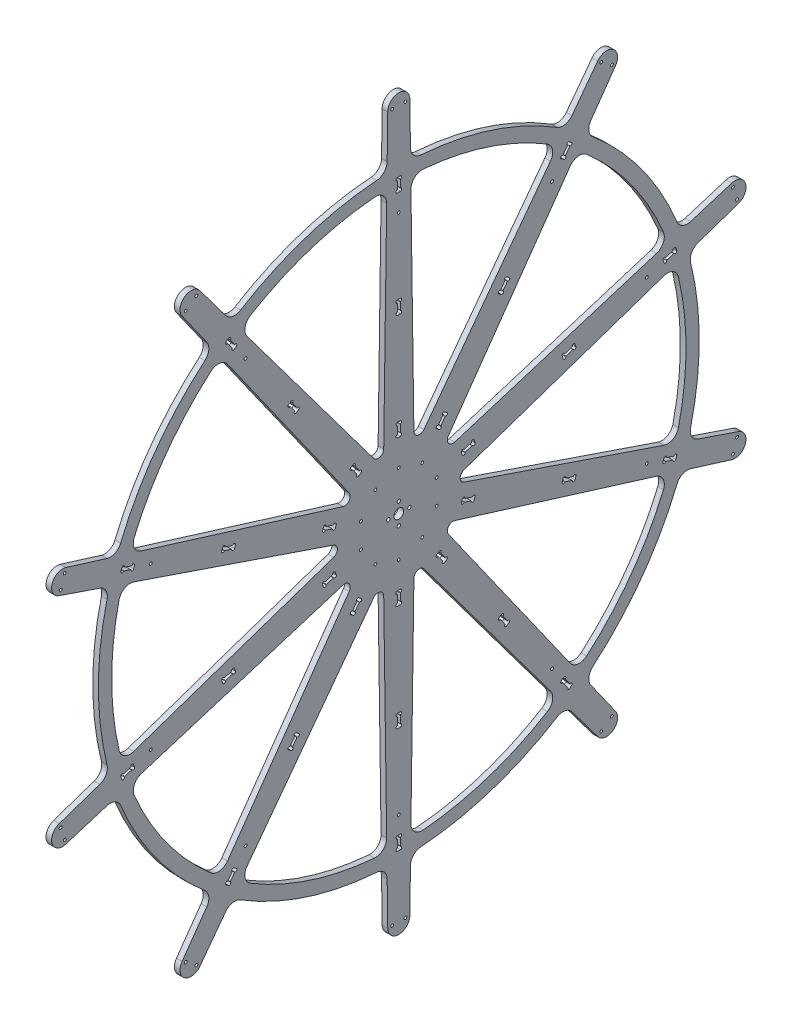
from build123d import *

# Parameters (mm, degrees)
SKETCH1_R                    = 45
BOSS_EXTRUDE1_DEPTH          = 3.175
BOSS_EXTRUDE2_START          = 3.175
SKETCH1_4_R                  = 1.5875
BOSS_EXTRUDE2_DEPTH          = 6.35
BOSS_EXTRUDE3_START          = 3.175
SKETCH2_R                    = 340
SKETCH2_R_2                  = 325
BOSS_EXTRUDE3_DEPTH          = 6.35
SKETCH1_5_R                  = 1.5875
SKETCH1_5_W                  = 3.375
SKETCH1_5_H                  = 15.2
CUT_EXTRUDE1_DEPTH           = 4.175
FILLET3_R                    = 12.7
FILLET4_R                    = 0.5
F_1_8_0_125_DIAMETER_HOLE1_D = 3.175
CIRPATTERN1_COUNT            = 10
FILLET3_OF_CIRPATTERN1_R     = 12.7
FILLET4_OF_CIRPATTERN1_R     = 0.5
M4_CLEARANCE_HOLE1_D         = 4
CIRPATTERN2_COUNT            = 4
F_1_8_0_125_DIAMETER_HOLE2_D = 3.175
SKETCH7_R                    = 5.5
CUT_EXTRUDE2_DEPTH           = 1
CUT_EXTRUDE2_DEPTH_BACK      = 7.35
FILLET1_R                    = 6.35
CIRPATTERN3_COUNT            = 10


with BuildPart() as part:
    # Sketch1 → Boss-Extrude1 (new body, symmetric)
    with BuildSketch(Plane(origin=(0, 0, 0), x_dir=(0, 0, -1), z_dir=(1, 0, 0))):
        Circle(SKETCH1_R)
    extrude(amount=BOSS_EXTRUDE1_DEPTH, both=True)

    # Sketch1_4 → Boss-Extrude2 (add)
    with BuildSketch(Plane(origin=(0, 0, 0), x_dir=(0, 0, -1), z_dir=(1, 0, 0)).offset(BOSS_EXTRUDE2_START)):
        with BuildLine():
            Line((12.5, -400), (17.5, -41.457809879))
            ThreePointArc((17.5, -41.457809879), (0, -45), (-17.5, -41.457809879))
            Line((-17.5, -41.457809879), (-12.5, -400))
            ThreePointArc((-12.5, -400), (0, -412.5), (12.5, -400))
        make_face()
        with Locations((-1.6875, -88.6125)):
            Circle(SKETCH1_4_R, mode=Mode.SUBTRACT)
        with Locations((-1.6875, -76.5875)):
            Circle(SKETCH1_4_R, mode=Mode.SUBTRACT)
        with Locations((1.6875, -76.5875)):
            Circle(SKETCH1_4_R, mode=Mode.SUBTRACT)
        with Locations((1.6875, -88.6125)):
            Circle(SKETCH1_4_R, mode=Mode.SUBTRACT)
        with Locations((-1.6875, -328.6125)):
            Circle(SKETCH1_4_R, mode=Mode.SUBTRACT)
        with Locations((-1.6875, -316.5875)):
            Circle(SKETCH1_4_R, mode=Mode.SUBTRACT)
        with Locations((1.6875, -316.5875)):
            Circle(SKETCH1_4_R, mode=Mode.SUBTRACT)
        with Locations((1.6875, -328.6125)):
            Circle(SKETCH1_4_R, mode=Mode.SUBTRACT)
        with Locations((-1.6875, -208.6125)):
            Circle(SKETCH1_4_R, mode=Mode.SUBTRACT)
        with Locations((-1.6875, -196.5875)):
            Circle(SKETCH1_4_R, mode=Mode.SUBTRACT)
        with Locations((1.6875, -196.5875)):
            Circle(SKETCH1_4_R, mode=Mode.SUBTRACT)
        with Locations((1.6875, -208.6125)):
            Circle(SKETCH1_4_R, mode=Mode.SUBTRACT)
    boss_extrude2 = extrude(amount=-BOSS_EXTRUDE2_DEPTH)

    # Sketch2 → Boss-Extrude3 (add)
    with BuildSketch(Plane(origin=(0, 0, 0), x_dir=(0, 0, -1), z_dir=(1, 0, 0)).offset(BOSS_EXTRUDE3_START)):
        Circle(SKETCH2_R)
        Circle(SKETCH2_R_2, mode=Mode.SUBTRACT)
    extrude(amount=-BOSS_EXTRUDE3_DEPTH)

    # Sketch1_5 → Cut-Extrude1 (cut, symmetric)
    with BuildSketch(Plane(origin=(0, 0, 0), x_dir=(0, 0, -1), z_dir=(1, 0, 0))):
        with Locations((-1.6875, -328.6125)):
            Circle(SKETCH1_5_R)
        with Locations((1.6875, -328.6125)):
            Circle(SKETCH1_5_R)
        with Locations((0, -202.6)):
            Rectangle(SKETCH1_5_W, SKETCH1_5_H)
        with Locations((0, -82.6)):
            Rectangle(SKETCH1_5_W, SKETCH1_5_H)
        with Locations((0, -322.6)):
            Rectangle(SKETCH1_5_W, SKETCH1_5_H)
    cut_extrude1 = extrude(amount=CUT_EXTRUDE1_DEPTH, both=True, mode=Mode.SUBTRACT)

    # Fillet3
    fillet3_edges = [part.edges().sort_by_distance(p)[0] for p in [
        (0, -324.717418323, 13.549842721),
        (0, -339.73818516, 13.340372716),
        (0, -324.717418323, -13.549842721),
        (0, -339.73818516, -13.340372716),
    ]]
    fillet(fillet3_edges, radius=FILLET3_R)

    # Fillet4
    fillet4_edges = [part.edges().sort_by_distance(p)[0] for p in [
        (0, -87.025, 1.6875),
        (0, -87.025, -1.6875),
        (0, -198.175, -1.6875),
        (0, -198.175, 1.6875),
        (0, -327.025, 1.6875),
        (0, -327.025, -1.6875),
        (0, -207.025, 1.6875),
        (0, -78.175, -1.6875),
        (0, -318.175, -1.6875),
        (0, -318.175, 1.6875),
        (0, -207.025, -1.6875),
        (0, -78.175, 1.6875),
    ]]
    fillet(fillet4_edges, radius=FILLET4_R)

    # 1_8 _0.125_ Diameter Hole1 (through all)
    with Locations(Plane(origin=(3.175, 0, 0), x_dir=(0, 0, -1), z_dir=(1, 0, 0))):
        with Locations((-7.5, -400), (7.5, -400)):
            f_1_8_0_125_diameter_hole1 = Hole(F_1_8_0_125_DIAMETER_HOLE1_D / 2)

    # CirPattern1: Boss-Extrude2, Cut-Extrude1, 1_8 _0.125_ Diameter Hole1 ×10 about axis
    cirpattern1_axis = Axis((0, 0, 0), (1, 0, 0))
    for i in range(1, CIRPATTERN1_COUNT):
        add(boss_extrude2.rotate(cirpattern1_axis, i * 360 / CIRPATTERN1_COUNT))
        add(cut_extrude1.rotate(cirpattern1_axis, i * 360 / CIRPATTERN1_COUNT), mode=Mode.SUBTRACT)
        add(f_1_8_0_125_diameter_hole1.rotate(cirpattern1_axis, i * 360 / CIRPATTERN1_COUNT), mode=Mode.SUBTRACT)

    # Fillet3 of CirPattern1
    fillet3_of_cirpattern1_edges = [part.edges().sort_by_distance(p)[0] for p in [
        (0, -270.666307515, -179.90205662),
        (0, -282.695239775, -188.900506639),
        (0, -254.737512071, -201.826162685),
        (0, -267.01269109, -210.485683116),
        (0, -113.229866846, -304.637484979),
        (0, -117.672321254, -318.98781295),
        (0, -87.456534417, -313.011748322),
        (0, -92.297424451, -327.232616711),
        (0, 87.456534417, -313.011748322),
        (0, 92.297424451, -327.232616711),
        (0, 113.229866846, -304.637484979),
        (0, 117.672321254, -318.98781295),
        (0, 254.737512071, -201.826162685),
        (0, 267.01269109, -210.485683116),
        (0, 270.666307515, -179.90205662),
        (0, 282.695239775, -188.900506639),
        (0, 324.717418323, -13.549842721),
        (0, 339.73818516, -13.340372716),
        (0, 324.717418323, 13.549842721),
        (0, 339.73818516, 13.340372716),
        (0, 270.666307515, 179.90205662),
        (0, 282.695239775, 188.900506639),
        (0, 254.737512071, 201.826162685),
        (0, 267.01269109, 210.485683116),
        (0, 113.229866846, 304.637484979),
        (0, 117.672321254, 318.98781295),
        (0, 87.456534417, 313.011748322),
        (0, 92.297424451, 327.232616711),
        (0, -87.456534417, 313.011748322),
        (0, -92.297424451, 327.232616711),
        (0, -113.229866846, 304.637484979),
        (0, -117.672321254, 318.98781295),
        (0, -254.737512071, 201.826162685),
        (0, -267.01269109, 210.485683116),
        (0, -270.666307515, 179.90205662),
        (0, -282.695239775, 188.900506639),
    ]]
    fillet(fillet3_of_cirpattern1_edges, radius=FILLET3_OF_CIRPATTERN1_R)

    # Fillet4 of CirPattern1
    fillet4_of_cirpattern1_edges = [part.edges().sort_by_distance(p)[0] for p in [
        (0, -71.396591549, -49.786795403),
        (0, -69.412816322, -52.517227759),
        (0, -159.335055247, -117.849558551),
        (0, -161.318830473, -115.119126195),
        (0, -265.560670199, -190.855255953),
        (0, -263.576894972, -193.585688309),
        (0, -168.478630874, -120.321025678),
        (0, -62.253015922, -47.315328276),
        (0, -256.417094572, -188.383788826),
        (0, -258.400869798, -185.65335647),
        (0, -166.494855647, -123.051458034),
        (0, -64.236791149, -44.58489592),
        (0, -28.497111807, -82.244227153),
        (0, -25.287296064, -83.287159509),
        (0, -59.634534989, -188.997091295),
        (0, -62.844350731, -187.954158939),
        (0, -102.661190457, -310.497791063),
        (0, -99.451374714, -311.540723419),
        (0, -65.579151132, -196.371009108),
        (0, -22.552495664, -74.870309339),
        (0, -96.716574314, -303.12387325),
        (0, -99.926390056, -302.080940894),
        (0, -62.369335389, -197.413941464),
        (0, -25.762311407, -73.827376983),
        (0, 25.287296064, -83.287159509),
        (0, 28.497111807, -82.244227153),
        (0, 62.844350732, -187.954158939),
        (0, 59.634534989, -188.997091295),
        (0, 99.451374714, -311.540723419),
        (0, 102.661190457, -310.497791063),
        (0, 62.369335389, -197.413941464),
        (0, 25.762311407, -73.827376983),
        (0, 99.926390057, -302.080940894),
        (0, 96.716574314, -303.12387325),
        (0, 65.579151132, -196.371009108),
        (0, 22.552495664, -74.870309339),
        (0, 69.412816322, -52.517227759),
        (0, 71.396591549, -49.786795403),
        (0, 161.318830474, -115.119126195),
        (0, 159.335055247, -117.849558551),
        (0, 263.576894972, -193.585688309),
        (0, 265.560670199, -190.855255953),
        (0, 166.494855647, -123.051458034),
        (0, 64.236791149, -44.58489592),
        (0, 258.400869799, -185.65335647),
        (0, 256.417094572, -188.383788826),
        (0, 168.478630874, -120.321025678),
        (0, 62.253015922, -47.315328276),
        (0, 87.025, -1.6875),
        (0, 87.025, 1.6875),
        (0, 198.175, 1.6875),
        (0, 198.175, -1.6875),
        (0, 327.025, -1.6875),
        (0, 327.025, 1.6875),
        (0, 207.025, -1.6875),
        (0, 78.175, 1.6875),
        (0, 318.175, 1.6875),
        (0, 318.175, -1.6875),
        (0, 207.025, 1.6875),
        (0, 78.175, -1.6875),
        (0, 71.396591549, 49.786795403),
        (0, 69.412816322, 52.517227759),
        (0, 159.335055247, 117.849558551),
        (0, 161.318830473, 115.119126195),
        (0, 265.560670199, 190.855255953),
        (0, 263.576894972, 193.585688309),
        (0, 168.478630874, 120.321025678),
        (0, 62.253015922, 47.315328276),
        (0, 256.417094572, 188.383788826),
        (0, 258.400869798, 185.65335647),
        (0, 166.494855647, 123.051458034),
        (0, 64.236791149, 44.58489592),
        (0, 28.497111807, 82.244227153),
        (0, 25.287296064, 83.287159509),
        (0, 59.634534989, 188.997091295),
        (0, 62.844350731, 187.954158939),
        (0, 102.661190457, 310.497791063),
        (0, 99.451374714, 311.540723419),
        (0, 65.579151132, 196.371009108),
        (0, 22.552495664, 74.870309339),
        (0, 96.716574314, 303.12387325),
        (0, 99.926390056, 302.080940894),
        (0, 62.369335389, 197.413941464),
        (0, 25.762311407, 73.827376983),
        (0, -25.287296064, 83.287159509),
        (0, -28.497111807, 82.244227153),
        (0, -62.844350732, 187.954158939),
        (0, -59.634534989, 188.997091295),
        (0, -99.451374714, 311.540723419),
        (0, -102.661190457, 310.497791063),
        (0, -62.369335389, 197.413941464),
        (0, -25.762311407, 73.827376983),
        (0, -99.926390057, 302.080940894),
        (0, -96.716574314, 303.12387325),
        (0, -65.579151132, 196.371009108),
        (0, -22.552495664, 74.870309339),
        (0, -69.412816322, 52.517227759),
        (0, -71.396591549, 49.786795403),
        (0, -161.318830474, 115.119126195),
        (0, -159.335055247, 117.849558551),
        (0, -263.576894972, 193.585688309),
        (0, -265.560670199, 190.855255953),
        (0, -166.494855647, 123.051458034),
        (0, -64.236791149, 44.58489592),
        (0, -258.400869799, 185.65335647),
        (0, -256.417094572, 188.383788826),
        (0, -168.478630874, 120.321025678),
        (0, -62.253015922, 47.315328276),
    ]]
    fillet(fillet4_of_cirpattern1_edges, radius=FILLET4_OF_CIRPATTERN1_R)

    # M4 Clearance Hole1 (through all)
    with Locations(Plane(origin=(-3.175, 0, 0), x_dir=(0, 0, -1), z_dir=(-1, 0, 0))):
        with Locations((0, -12)):
            m4_clearance_hole1 = Hole(M4_CLEARANCE_HOLE1_D / 2)

    # CirPattern2: M4 Clearance Hole1 ×4 about axis
    cirpattern2_axis = Axis((0, 0, 0), (1, 0, 0))
    for i in range(1, CIRPATTERN2_COUNT):
        add(m4_clearance_hole1.rotate(cirpattern2_axis, i * 360 / CIRPATTERN2_COUNT), mode=Mode.SUBTRACT)

    # 1_8 _0.125_ Diameter Hole2 (through all)
    with Locations(Plane.ZY.offset(3.175)):
        with Locations((0, -295.1), (0, -45.1)):
            f_1_8_0_125_diameter_hole2 = Hole(F_1_8_0_125_DIAMETER_HOLE2_D / 2)

    # Sketch7 → Cut-Extrude2 (cut, two sides)
    with BuildSketch(Plane(origin=(3.175, 0, 0), x_dir=(0, 0, -1), z_dir=(1, 0, 0))) as cut_extrude2_sk:
        Circle(SKETCH7_R)
    extrude(amount=CUT_EXTRUDE2_DEPTH, mode=Mode.SUBTRACT)
    extrude(cut_extrude2_sk.sketch, amount=-CUT_EXTRUDE2_DEPTH_BACK, mode=Mode.SUBTRACT)

    # Fillet1
    fillet1_edges = [part.edges().sort_by_distance(p)[0] for p in [
        (0, -32.971553986, 45.381450796),
        (0, -53.349095011, 17.334171745),
        (0, 0, 56.094558101),
        (0, 32.971553986, 45.381450796),
        (0, 53.349095011, 17.334171745),
        (0, 53.349095011, -17.334171745),
        (0, 32.971553986, -45.381450796),
        (0, 0, -56.094558101),
        (0, -32.971553986, -45.381450796),
        (0, -53.349095011, -17.334171745),
    ]]
    fillet(fillet1_edges, radius=FILLET1_R)

    # CirPattern3: 1_8 _0.125_ Diameter Hole2 ×10 about axis
    cirpattern3_axis = Axis((0, 0, 0), (1, 0, 0))
    for i in range(1, CIRPATTERN3_COUNT):
        add(f_1_8_0_125_diameter_hole2.rotate(cirpattern3_axis, i * 360 / CIRPATTERN3_COUNT), mode=Mode.SUBTRACT)


solid = part.part
